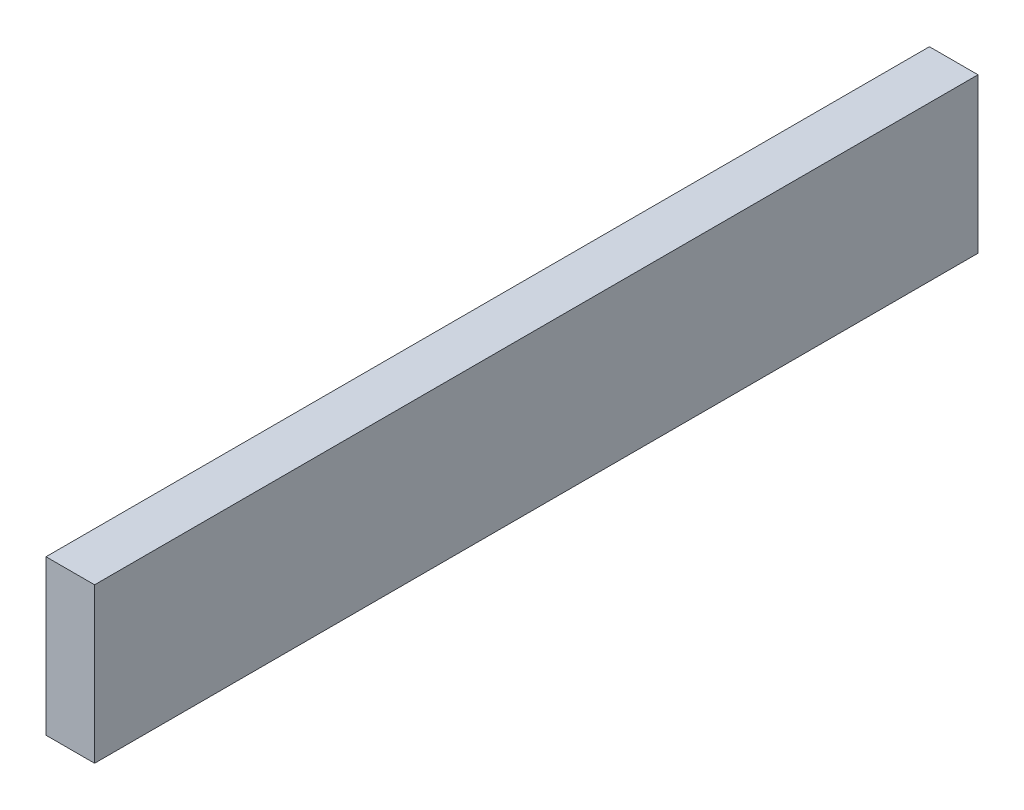
from build123d import *

# Parameters (mm, degrees)
ESQUISSE1_W      = 22
ESQUISSE1_H      = 400
EXTRUSION1_DEPTH = 70


with BuildPart() as part:
    # Esquisse1 → Extrusion1 (new body)
    with BuildSketch(Plane(origin=(0, 0, 0), x_dir=(1, 0, 0), z_dir=(0, 1, 0))):
        with Locations((11, 200)):
            Rectangle(ESQUISSE1_W, ESQUISSE1_H)
    extrude(amount=EXTRUSION1_DEPTH)


solid = part.part
